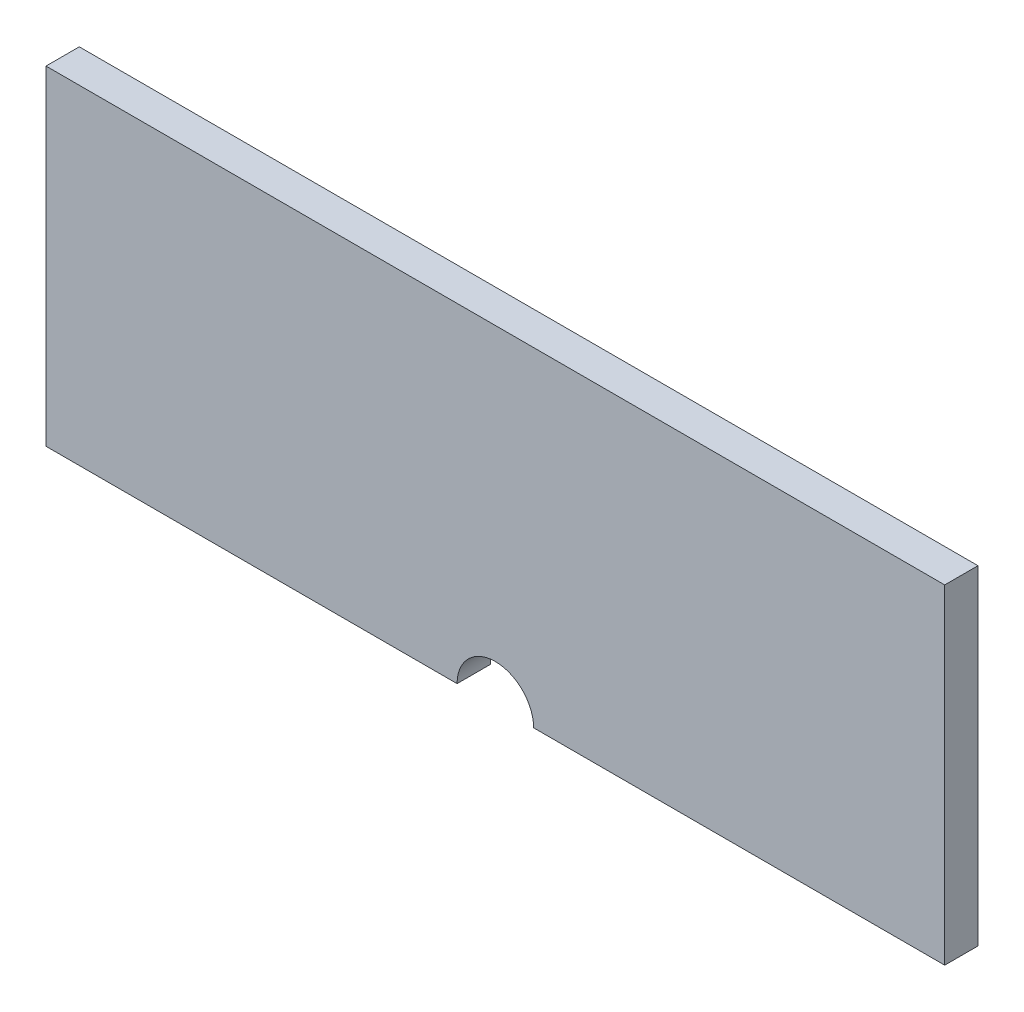
from build123d import *

# Parameters (mm, degrees)
BOSS_EXTRUDE1_DEPTH = 5


with BuildPart() as part:
    # Sketch1 → Boss-Extrude1 (new body, symmetric)
    with BuildSketch(Plane.XY):
        with BuildLine():
            Line((-11.5, -54.47), (-135, -54.47))
            Line((-135, -54.47), (-135, 44.47))
            Line((-135, 44.47), (135, 44.47))
            Line((135, 44.47), (135, -54.47))
            Line((135, -54.47), (11.5, -54.47))
            ThreePointArc((11.5, -54.47), (0, -42.97), (-11.5, -54.47))
        make_face()
    extrude(amount=BOSS_EXTRUDE1_DEPTH, both=True)


solid = part.part
